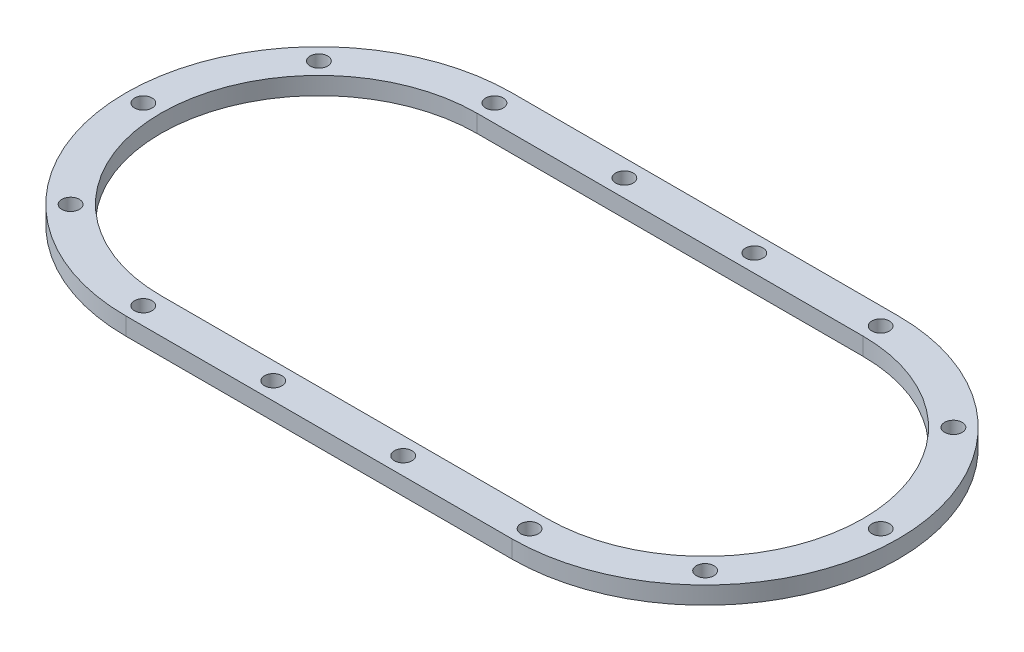
from build123d import *

# Parameters (mm, degrees)
BOSS_EXTRUDE1_DEPTH    = 10
F_10_0MM_DOWEL_HOLE6_D = 10
CIRPATTERN2_COUNT      = 5
CIRPATTERN2_ANGLE      = 180
MIRROR2_COPY_1_D       = 10
MIRROR2_COPY_2_D       = 10
MIRROR2_COPY_3_D       = 10
MIRROR2_COPY_4_D       = 10
LPATTERN1_COUNT        = 3
LPATTERN1_PITCH        = 74
MIRROR3_COPY_1_D       = 10
MIRROR3_COPY_2_D       = 10
MIRROR3_COPY_3_D       = 10


with BuildPart() as part:
    # Sketch1 → Boss-Extrude1 (new body)
    with BuildSketch(Plane(origin=(0, 0, 0), x_dir=(1, 0, 0), z_dir=(0, 1, 0))):
        with BuildLine():
            Line((-110, 110), (110, 110))
            ThreePointArc((110, 110), (220, 0), (110, -110))
            Line((110, -110), (-110, -110))
            ThreePointArc((-110, -110), (-220, 0), (-110, 110))
        make_face()
        with BuildLine():
            Line((-110, 90), (110, 90))
            ThreePointArc((110, 90), (200, 0), (110, -90))
            Line((110, -90), (-110, -90))
            ThreePointArc((-110, -90), (-200, 0), (-110, 90))
        make_face(mode=Mode.SUBTRACT)
    extrude(amount=BOSS_EXTRUDE1_DEPTH)

    # Ø10.0mm Dowel Hole6 (through all)
    with Locations(Plane(origin=(-110, 10, -100), x_dir=(0, 0, 1), z_dir=(0, 1, 0))):
        with Locations((0, 0)):
            f_10_0mm_dowel_hole6 = Hole(F_10_0MM_DOWEL_HOLE6_D / 2)

    # CirPattern2: Ø10.0mm Dowel Hole6 ×5 about axis
    cirpattern2_axis = Axis((-110, 0, 0), (0, 1, 0))
    for i in range(1, CIRPATTERN2_COUNT):
        add(f_10_0mm_dowel_hole6.rotate(cirpattern2_axis, i * CIRPATTERN2_ANGLE / (CIRPATTERN2_COUNT - 1)), mode=Mode.SUBTRACT)

    # Mirror2: Ø10.0mm Dowel Hole6 across plane
    add(f_10_0mm_dowel_hole6.mirror(Plane(origin=(0, 0, 0), x_dir=(0, 0, 1), z_dir=(1, 0, 0))), mode=Mode.SUBTRACT)

    # Mirror2 copy 1 (through all)
    with Locations(Plane(origin=(180.710678119, 10, -70.710678119), x_dir=(-0.707106781, 0, 0.707106781), z_dir=(0, 1, 0))):
        with Locations((0, 0)):
            Hole(MIRROR2_COPY_1_D / 2)

    # Mirror2 copy 2 (through all)
    with Locations(Plane(origin=(210, 10, 0), x_dir=(-1, 0, 0), z_dir=(0, 1, 0))):
        with Locations((0, 0)):
            Hole(MIRROR2_COPY_2_D / 2)

    # Mirror2 copy 3 (through all)
    with Locations(Plane(origin=(180.710678119, 10, 70.710678119), x_dir=(-0.707106781, 0, -0.707106781), z_dir=(0, 1, 0))):
        with Locations((0, 0)):
            Hole(MIRROR2_COPY_3_D / 2)

    # Mirror2 copy 4 (through all)
    with Locations(Plane(origin=(110, 10, 100), x_dir=(0, 0, -1), z_dir=(0, 1, 0))):
        with Locations((0, 0)):
            Hole(MIRROR2_COPY_4_D / 2)

    # LPattern1: Ø10.0mm Dowel Hole6 ×3
    with Locations(*[(i * LPATTERN1_PITCH, 0, 0) for i in range(1, LPATTERN1_COUNT)]):
        add(f_10_0mm_dowel_hole6, mode=Mode.SUBTRACT)

    # Mirror3 copy 1 (through all)
    with Locations(Plane(origin=(-36, 10, 100), x_dir=(0, 0, -1), z_dir=(0, 1, 0))):
        with Locations((0, 0)):
            Hole(MIRROR3_COPY_1_D / 2)

    # Mirror3 copy 2 (through all)
    with Locations(Plane(origin=(38, 10, 100), x_dir=(0, 0, -1), z_dir=(0, 1, 0))):
        with Locations((0, 0)):
            Hole(MIRROR3_COPY_2_D / 2)

    # Mirror3 copy 3 (through all)
    with Locations(Plane(origin=(-110, 10, 100), x_dir=(0, 0, -1), z_dir=(0, 1, 0))):
        with Locations((0, 0)):
            Hole(MIRROR3_COPY_3_D / 2)


solid = part.part
